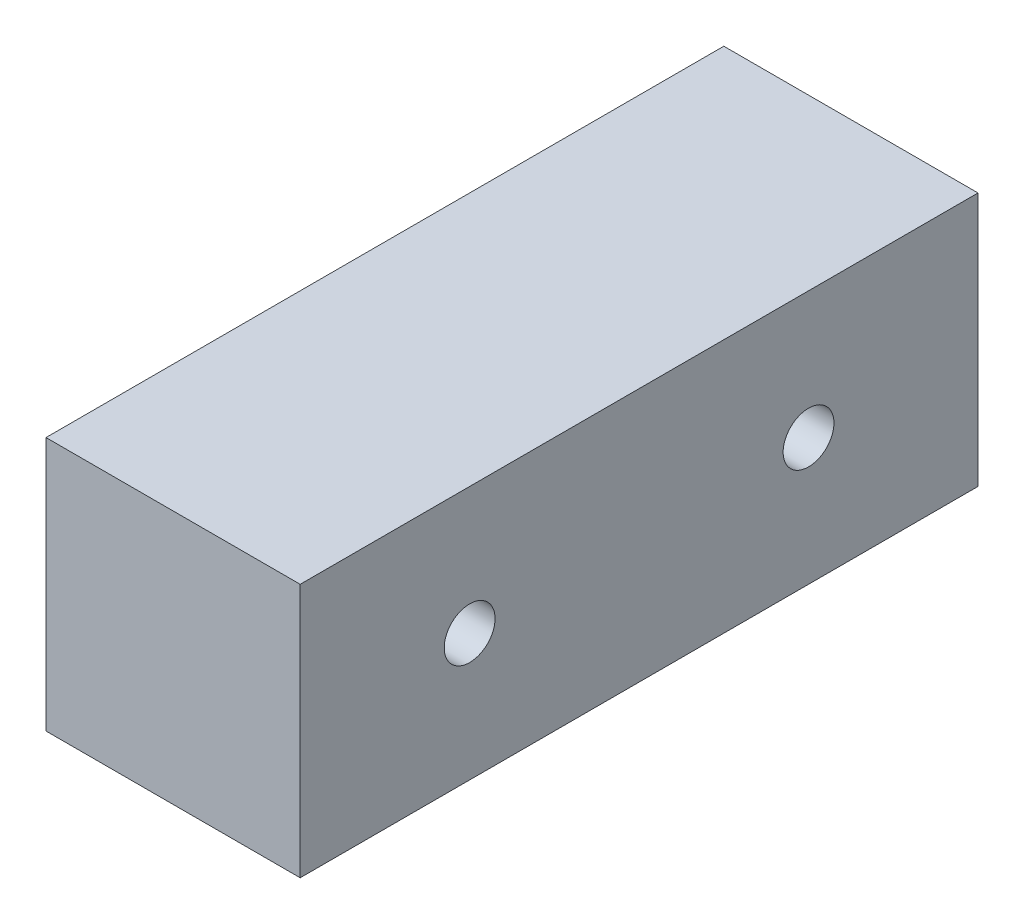
from build123d import *

# Parameters (mm, degrees)
SKETCH1_W           = 150
SKETCH1_H           = 400
BOSS_EXTRUDE1_DEPTH = 150
SKETCH2_R           = 15
CUT_EXTRUDE1_DEPTH  = 151


with BuildPart() as part:
    # Sketch1 → Boss-Extrude1 (new body)
    with BuildSketch(Plane(origin=(0, 0, 0), x_dir=(1, 0, 0), z_dir=(0, 1, 0))):
        Rectangle(SKETCH1_W, SKETCH1_H)
    extrude(amount=BOSS_EXTRUDE1_DEPTH)

    # Sketch2 → Cut-Extrude1 (cut, through all)
    with BuildSketch(Plane(origin=(75, 0, 0), x_dir=(0, 0, -1), z_dir=(1, 0, 0))):
        with Locations((-100, 75)):
            Circle(SKETCH2_R)
        with Locations((100, 75)):
            Circle(SKETCH2_R)
    extrude(amount=-CUT_EXTRUDE1_DEPTH, mode=Mode.SUBTRACT)


solid = part.part
